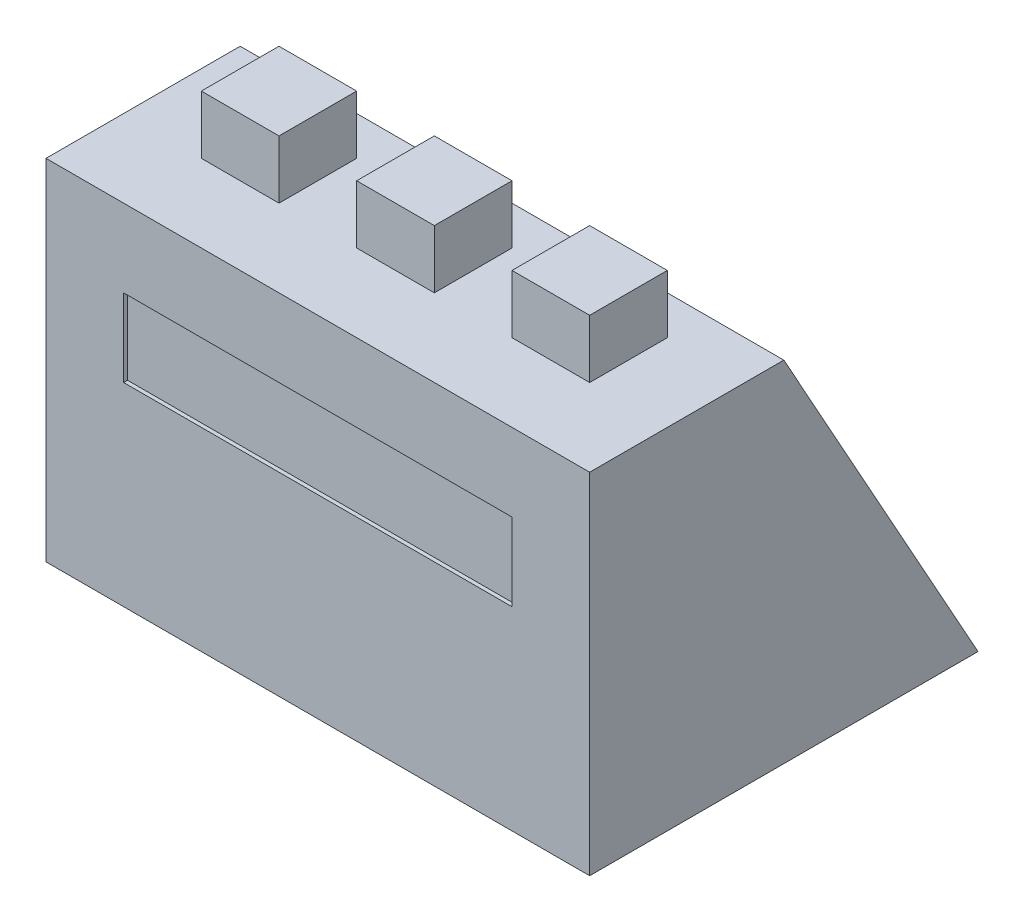
from build123d import *

# Parameters (mm, degrees)
EXTRUDE1_DEPTH     = 140
SKETCH2_W          = 100
SKETCH2_H          = 20
CUT_EXTRUDE1_DEPTH = 1
SKETCH3_W          = 20
SKETCH3_H          = 20
EXTRUDE2_DEPTH     = 15
EXTRUDE2_2_DEPTH   = 15
EXTRUDE2_3_DEPTH   = 15


with BuildPart() as part:
    # Sketch1 → Extrude1 (new body)
    with BuildSketch(Plane(origin=(0, 0, 0), x_dir=(0, 0, -1), z_dir=(1, 0, 0))):
        Polygon((0, 90), (0, 0), (100, 0), (50, 90), align=None)
    extrude(amount=EXTRUDE1_DEPTH)

    # Sketch2 → Cut-Extrude1 (cut)
    with BuildSketch(Plane.XY):
        with Locations((70, 60)):
            Rectangle(SKETCH2_W, SKETCH2_H)
    extrude(amount=-CUT_EXTRUDE1_DEPTH, mode=Mode.SUBTRACT)


with BuildPart() as body_2:
    # Sketch3 → Extrude2 (new body)
    with BuildSketch(Plane(origin=(0, 90, 0), x_dir=(-1, 0, 0), z_dir=(0, 1, 0))):
        with Locations((-30, -30)):
            Rectangle(SKETCH3_W, SKETCH3_H)
    extrude(amount=EXTRUDE2_DEPTH)


with BuildPart() as body_3:
    # Sketch3 → Extrude2 2 (new body)
    with BuildSketch(Plane(origin=(0, 90, 0), x_dir=(-1, 0, 0), z_dir=(0, 1, 0))):
        with Locations((-70, -30)):
            Rectangle(SKETCH3_W, SKETCH3_H)
    extrude(amount=EXTRUDE2_2_DEPTH)


with BuildPart() as body_4:
    # Sketch3 → Extrude2 3 (new body)
    with BuildSketch(Plane(origin=(0, 90, 0), x_dir=(-1, 0, 0), z_dir=(0, 1, 0))):
        with Locations((-110, -30)):
            Rectangle(SKETCH3_W, SKETCH3_H)
    extrude(amount=EXTRUDE2_3_DEPTH)


solid = Compound([part.part, body_2.part, body_3.part, body_4.part])
